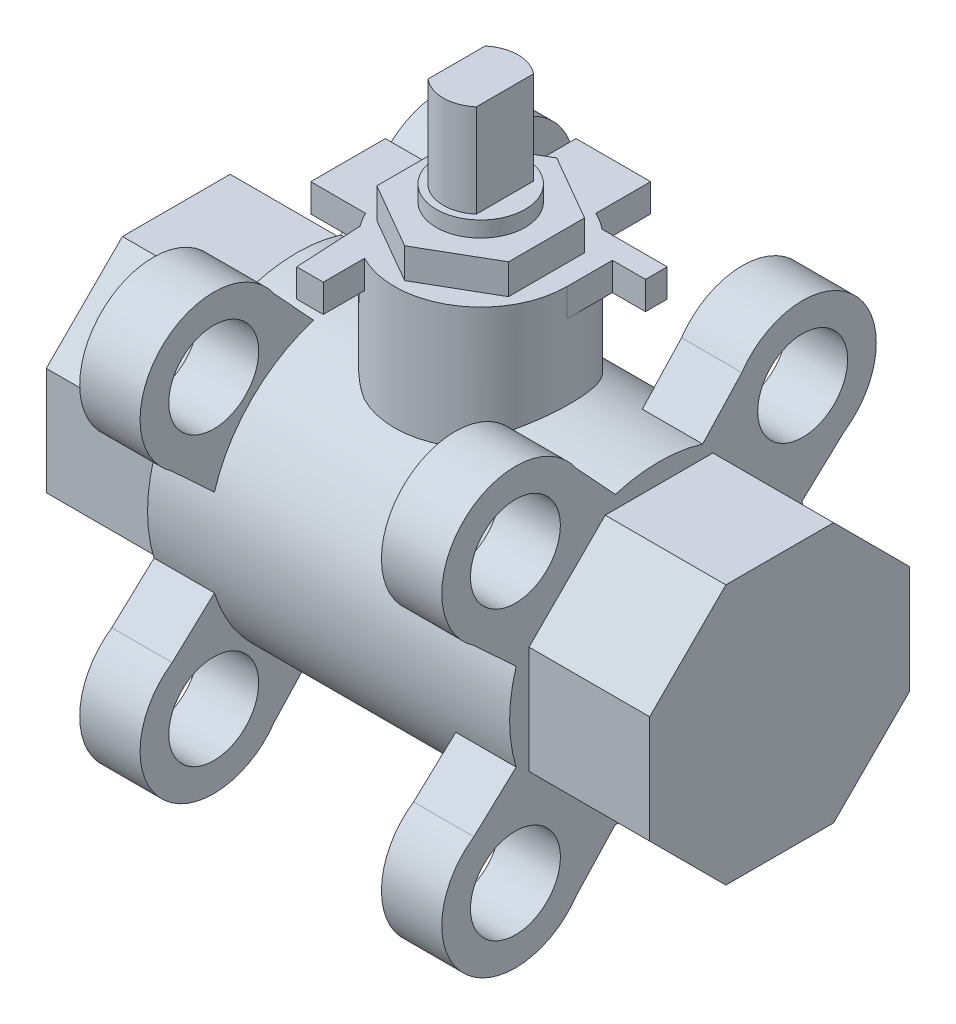
from build123d import *

# Parameters (mm, degrees)
SKETCH1_R            = 4.73075
BOSS_EXTRUDE2_DEPTH  = 6.35
BOSS_EXTRUDE3_DEPTH  = 12.7
SKETCH3_R            = 15.7226
BOSS_EXTRUDE4_DEPTH  = 25.4
SKETCH4_R            = 4.73075
BOSS_EXTRUDE5_DEPTH  = 6.35
BOSS_EXTRUDE6_DEPTH  = 12.7
SKETCH6_R            = 9.0805
BOSS_EXTRUDE8_DEPTH  = 12.8778
SKETCH8_W            = 7.8486
SKETCH8_H            = 8.0772
SKETCH8_W_2          = 8.0772
SKETCH8_H_2          = 7.8486
BOSS_EXTRUDE9_DEPTH  = 2.9464
BOSS_EXTRUDE10_DEPTH = 2.9464
BOSS_EXTRUDE11_DEPTH = 3.175
SKETCH12_R           = 4.6736
BOSS_EXTRUDE12_DEPTH = 1.651
BOSS_EXTRUDE13_DEPTH = 9.779


with BuildPart() as part:
    # Sketch1 → Boss-Extrude2 (new body)
    with BuildSketch(Plane(origin=(0, 0, 0), x_dir=(0, 0, -1), z_dir=(1, 0, 0))):
        with BuildLine():
            Line((-19.4818, 8.715375788), (-15.0368, 4.592907197))
            ThreePointArc((-15.0368, 4.592907197), (-15.7226, 0), (-15.0368, -4.592907197))
            Line((-15.0368, -4.592907197), (-19.4818, -8.715375788))
            ThreePointArc((-19.4818, -8.715375788), (-20.590956234, -20.590956234), (-8.715375788, -19.4818))
            Line((-8.715375788, -19.4818), (-4.592907197, -15.0368))
            ThreePointArc((-4.592907197, -15.0368), (0, -15.7226), (4.592907197, -15.0368))
            Line((4.592907197, -15.0368), (8.715375788, -19.4818))
            ThreePointArc((8.715375788, -19.4818), (20.590956234, -20.590956234), (19.4818, -8.715375788))
            Line((19.4818, -8.715375788), (15.0368, -4.592907197))
            ThreePointArc((15.0368, -4.592907197), (15.7226, 0), (15.0368, 4.592907197))
            Line((15.0368, 4.592907197), (19.4818, 8.715375788))
            ThreePointArc((19.4818, 8.715375788), (20.590956234, 20.590956234), (8.715375788, 19.4818))
            Line((8.715375788, 19.4818), (4.592907197, 15.0368))
            ThreePointArc((4.592907197, 15.0368), (0, 15.7226), (-4.592907197, 15.0368))
            Line((-4.592907197, 15.0368), (-8.715375788, 19.4818))
            ThreePointArc((-8.715375788, 19.4818), (-20.590956234, 20.590956234), (-19.4818, 8.715375788))
        make_face()
        with Locations((-15.113, 15.113)):
            Circle(SKETCH1_R, mode=Mode.SUBTRACT)
        with Locations((15.113, 15.113)):
            Circle(SKETCH1_R, mode=Mode.SUBTRACT)
        with Locations((15.113, -15.113)):
            Circle(SKETCH1_R, mode=Mode.SUBTRACT)
        with Locations((-15.113, -15.113)):
            Circle(SKETCH1_R, mode=Mode.SUBTRACT)
    extrude(amount=BOSS_EXTRUDE2_DEPTH)

    # Sketch2 → Boss-Extrude3 (add)
    with BuildSketch(Plane.ZY):
        Polygon((13.680992893, 5.666852803), (13.680992893, -5.666852803), (5.666852803, -13.680992893), (-5.666852803, -13.680992893), (-13.680992893, -5.666852803), (-13.680992893, 5.666852803), (-5.666852803, 13.680992893), (5.666852803, 13.680992893), align=None)
    extrude(amount=BOSS_EXTRUDE3_DEPTH)

    # Sketch3 → Boss-Extrude4 (add)
    with BuildSketch(Plane(origin=(6.35, 0, 0), x_dir=(0, 0, -1), z_dir=(1, 0, 0))):
        Circle(SKETCH3_R)
    extrude(amount=BOSS_EXTRUDE4_DEPTH)

    # Sketch4 → Boss-Extrude5 (add)
    with BuildSketch(Plane(origin=(31.75, 0, 0), x_dir=(0, 0, -1), z_dir=(1, 0, 0))):
        with BuildLine():
            Line((-19.4818, 8.715375788), (-15.0368, 4.592907197))
            ThreePointArc((-15.0368, 4.592907197), (-15.7226, 0), (-15.0368, -4.592907197))
            Line((-15.0368, -4.592907197), (-19.4818, -8.715375788))
            ThreePointArc((-19.4818, -8.715375788), (-20.590956234, -20.590956234), (-8.715375788, -19.4818))
            Line((-8.715375788, -19.4818), (-4.592907197, -15.0368))
            ThreePointArc((-4.592907197, -15.0368), (0, -15.7226), (4.592907197, -15.0368))
            Line((4.592907197, -15.0368), (8.715375788, -19.4818))
            ThreePointArc((8.715375788, -19.4818), (20.590956234, -20.590956234), (19.4818, -8.715375788))
            Line((19.4818, -8.715375788), (15.0368, -4.592907197))
            ThreePointArc((15.0368, -4.592907197), (15.7226, 0), (15.0368, 4.592907197))
            Line((15.0368, 4.592907197), (19.4818, 8.715375788))
            ThreePointArc((19.4818, 8.715375788), (20.590956234, 20.590956234), (8.715375788, 19.4818))
            Line((8.715375788, 19.4818), (4.592907197, 15.0368))
            ThreePointArc((4.592907197, 15.0368), (0, 15.7226), (-4.592907197, 15.0368))
            Line((-4.592907197, 15.0368), (-8.715375788, 19.4818))
            ThreePointArc((-8.715375788, 19.4818), (-20.590956234, 20.590956234), (-19.4818, 8.715375788))
        make_face()
        with Locations((-15.113, 15.113)):
            Circle(SKETCH4_R, mode=Mode.SUBTRACT)
        with Locations((15.113, 15.113)):
            Circle(SKETCH4_R, mode=Mode.SUBTRACT)
        with Locations((15.113, -15.113)):
            Circle(SKETCH4_R, mode=Mode.SUBTRACT)
        with Locations((-15.113, -15.113)):
            Circle(SKETCH4_R, mode=Mode.SUBTRACT)
    extrude(amount=BOSS_EXTRUDE5_DEPTH)

    # Sketch5 → Boss-Extrude6 (add)
    with BuildSketch(Plane(origin=(38.1, 0, 0), x_dir=(0, 0, -1), z_dir=(1, 0, 0))):
        Polygon((13.680992893, 5.666852803), (13.680992893, -5.666852803), (5.666852803, -13.680992893), (-5.666852803, -13.680992893), (-13.680992893, -5.666852803), (-13.680992893, 5.666852803), (-5.666852803, 13.680992893), (5.666852803, 13.680992893), align=None)
    extrude(amount=BOSS_EXTRUDE6_DEPTH)

    # Sketch6 → Boss-Extrude8 (add)
    with BuildSketch(Plane(origin=(0, 13.680992893, 0), x_dir=(1, 0, 0), z_dir=(0, 1, 0))):
        with Locations((19.05, 0.284018035)):
            Circle(SKETCH6_R)
    extrude(amount=BOSS_EXTRUDE8_DEPTH)

    # Sketch8 → Boss-Extrude9 (add)
    with BuildSketch(Plane(origin=(0, 26.558792893, 0), x_dir=(1, 0, 0), z_dir=(0, 1, 0))):
        with Locations((19.05, 10.202718035)):
            Rectangle(SKETCH8_W, SKETCH8_H)
        with Locations((9.1313, 0.284018035)):
            Rectangle(SKETCH8_W_2, SKETCH8_H_2)
    extrude(amount=-BOSS_EXTRUDE9_DEPTH)

    # Sketch10 → Boss-Extrude10 (add)
    with BuildSketch(Plane(origin=(0, 26.558792893, 0), x_dir=(1, 0, 0), z_dir=(0, 1, 0))):
        with BuildLine():
            Line((24.7523, 7.350789218), (31.6103, 7.350789218))
            Line((31.6103, 7.350789218), (31.6103, 5.064789218))
            Line((31.6103, 5.064789218), (28.1305, 5.064789218))
            Line((28.1305, 5.064789218), (28.1305, 0.284018035))
            ThreePointArc((28.1305, 0.284018035), (23.784459378, -7.464554392), (14.90647607, -7.795999892))
            Line((14.90647607, -7.795999892), (14.90647607, -12.140453608))
            Line((14.90647607, -12.140453608), (12.11247607, -12.140453608))
            Line((12.11247607, -12.140453608), (11.743935589, -5.108282316))
            ThreePointArc((11.743935589, -5.108282316), (12.769066077, 6.841864427), (24.7523, 7.350789218))
        make_face()
    extrude(amount=-BOSS_EXTRUDE10_DEPTH)

    # Sketch11 → Boss-Extrude11 (add)
    with BuildSketch(Plane(origin=(0, 26.558792893, 0), x_dir=(1, 0, 0), z_dir=(0, 1, 0))):
        Polygon((19.05, 8.285018035), (12.120930744, 4.284518035), (12.120930744, -3.716481965), (19.05, -7.716981965), (25.979069256, -3.716481965), (25.979069256, 4.284518035), align=None)
    extrude(amount=BOSS_EXTRUDE11_DEPTH)

    # Sketch12 → Boss-Extrude12 (add)
    with BuildSketch(Plane(origin=(0, 29.733792893, 0), x_dir=(1, 0, 0), z_dir=(0, 1, 0))):
        with Locations((19.05, 0.284018035)):
            Circle(SKETCH12_R)
    extrude(amount=BOSS_EXTRUDE12_DEPTH)

    # Sketch13 → Boss-Extrude13 (add)
    with BuildSketch(Plane(origin=(0, 31.384792893, 0), x_dir=(1, 0, 0), z_dir=(0, 1, 0))):
        with BuildLine():
            Line((16.51, 3.292068732), (16.51, -2.724032663))
            ThreePointArc((16.51, -2.724032663), (19.05, -3.652981965), (21.59, -2.724032663))
            Line((21.59, -2.724032663), (21.59, 3.292068732))
            ThreePointArc((21.59, 3.292068732), (19.05, 4.221018035), (16.51, 3.292068732))
        make_face()
    extrude(amount=BOSS_EXTRUDE13_DEPTH)


solid = part.part
